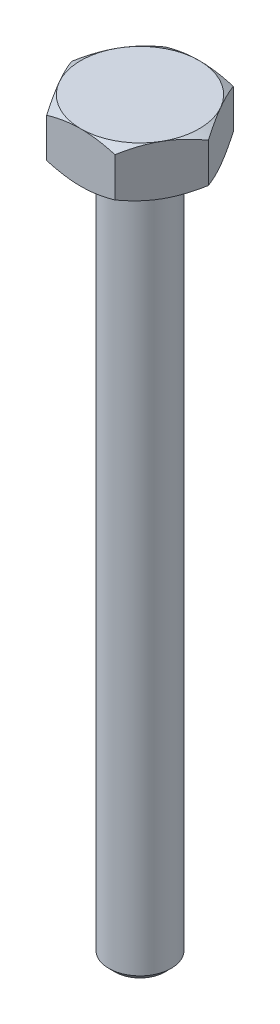
from build123d import *

# Parameters (mm, degrees)
SALIENTE_EXTRUIR1_DEPTH = 8
CROQUIS2_R              = 4.25
CORTAR_EXTRUIR1_DEPTH   = 9
CROQUIS3_OUTSIDE_W      = 57.674
CROQUIS3_OUTSIDE_H      = 54.734
CROQUIS3_OUTSIDE_R      = 9.5
CORTAR_EXTRUIR2_DEPTH   = 8
CORTAR_EXTRUIR2_TAPER   = 60
CROQUIS4_OUTSIDE_W      = 57.674
CROQUIS4_OUTSIDE_H      = 54.734
CROQUIS4_OUTSIDE_R      = 9.5
CORTAR_EXTRUIR3_DEPTH   = 8
CORTAR_EXTRUIR3_TAPER   = 60
CROQUIS5_R              = 5
SALIENTE_EXTRUIR3_DEPTH = 120
CHAFL_N2_SIZE           = 1


with BuildPart() as part:
    # Croquis1 → Saliente-Extruir1 (new body)
    with BuildSketch(Plane(origin=(0, 0, 0), x_dir=(1, 0, 0), z_dir=(0, 1, 0))):
        Polygon((10.969655115, 0), (5.484827557, 9.5), (-5.484827557, 9.5), (-10.969655115, 0), (-5.484827557, -9.5), (5.484827557, -9.5), align=None)
    extrude(amount=SALIENTE_EXTRUIR1_DEPTH)

    # Croquis2 → Cortar-Extruir1 (cut, through all)
    with BuildSketch(Plane(origin=(0, 8, 0), x_dir=(1, 0, 0), z_dir=(0, 1, 0))):
        Circle(CROQUIS2_R)
    extrude(amount=-CORTAR_EXTRUIR1_DEPTH, mode=Mode.SUBTRACT)

    # Croquis3 outside → Cortar-Extruir2 (cut)
    with BuildSketch(Plane(origin=(0, 8, 0), x_dir=(1, 0, 0), z_dir=(0, 1, 0))):
        Rectangle(CROQUIS3_OUTSIDE_W, CROQUIS3_OUTSIDE_H)
        Circle(CROQUIS3_OUTSIDE_R, mode=Mode.SUBTRACT)
    extrude(amount=-CORTAR_EXTRUIR2_DEPTH, taper=CORTAR_EXTRUIR2_TAPER, mode=Mode.SUBTRACT)

    # Croquis4 outside → Cortar-Extruir3 (cut)
    with BuildSketch(Plane.XZ):
        Rectangle(CROQUIS4_OUTSIDE_W, CROQUIS4_OUTSIDE_H)
        Circle(CROQUIS4_OUTSIDE_R, mode=Mode.SUBTRACT)
    extrude(amount=-CORTAR_EXTRUIR3_DEPTH, taper=CORTAR_EXTRUIR3_TAPER, mode=Mode.SUBTRACT)

    # Croquis5 → Saliente-Extruir3 (add)
    with BuildSketch(Plane(origin=(0, 8, 0), x_dir=(1, 0, 0), z_dir=(0, 1, 0))):
        Circle(CROQUIS5_R)
    extrude(amount=-SALIENTE_EXTRUIR3_DEPTH)

    # Chaflán2
    chafl_n2_edges = [part.edges().sort_by_distance(p)[0] for p in [
        (-5, -112, 0),
    ]]
    chamfer(chafl_n2_edges, length=CHAFL_N2_SIZE)


solid = part.part
